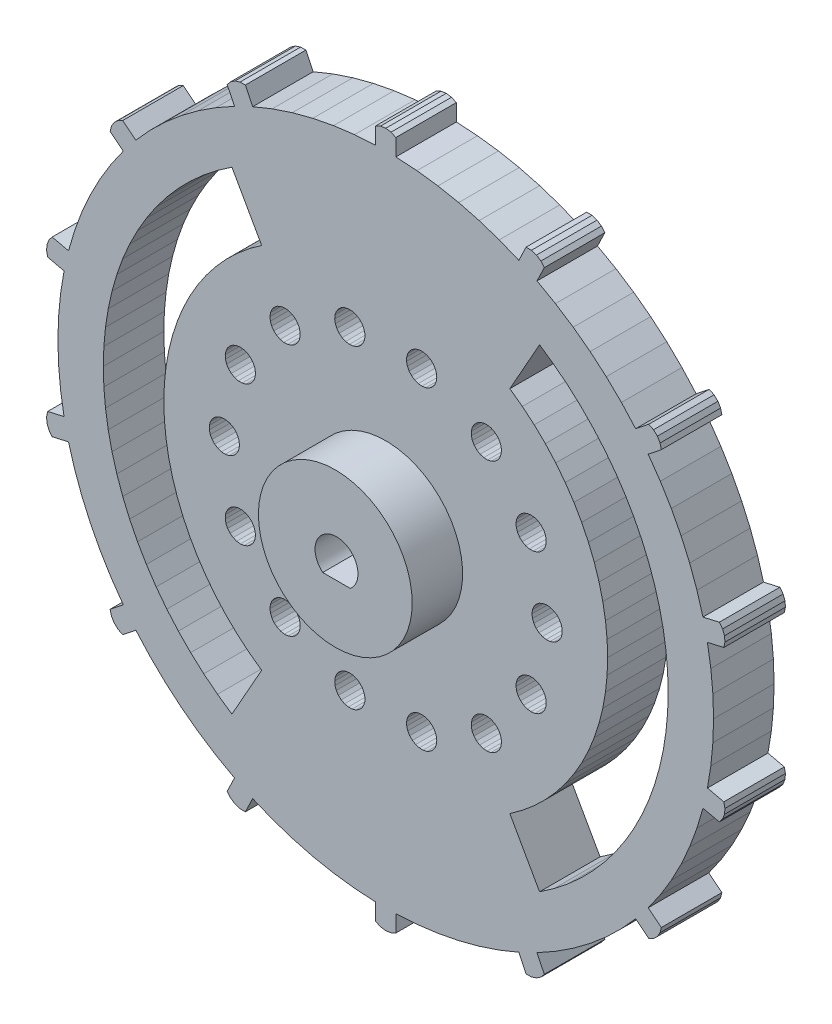
from build123d import *

# Parameters (mm, degrees)
BOSS_EXTRUDE1_DEPTH = 6.000000052
CUT_EXTRUDE1_DEPTH  = 7.000000052
CUT_EXTRUDE2_DEPTH  = 7.000000052
CUT_EXTRUDE3_DEPTH  = 7.000000052
CUT_EXTRUDE4_DEPTH  = 7.000000052
CUT_EXTRUDE5_DEPTH  = 7.000000052
CUT_EXTRUDE6_DEPTH  = 7.000000052
CUT_EXTRUDE7_DEPTH  = 7.000000052
CUT_EXTRUDE8_DEPTH  = 7.000000052
CUT_EXTRUDE9_DEPTH  = 7.000000052
CUT_EXTRUDE10_DEPTH = 7.000000052
CUT_EXTRUDE11_DEPTH = 7.000000052
CUT_EXTRUDE12_DEPTH = 7.000000052
CUT_EXTRUDE13_DEPTH = 7.000000052
CUT_EXTRUDE14_DEPTH = 7.000000052
CUT_EXTRUDE15_DEPTH = 7.000000052
CUT_EXTRUDE16_DEPTH = 7.000000052
SKETCH18_R          = 8.127
CUT_EXTRUDE17_DEPTH = 3.500000108
SKETCH19_R          = 7.623
BOSS_EXTRUDE2_DEPTH = 4.999999888
CUT_EXTRUDE18_DEPTH = 6.99999975


with BuildPart() as part:
    # Sketch1 → Boss-Extrude1 (new body)
    with BuildSketch(Plane.XY.offset(6.000000052)):
        Polygon((26.548104361, -21.838512272), (26.932541281, -21.477984264), (27.198484167, -21.022962406), (27.323946357, -20.511072129), (26.020983234, -19.471991807), (27.222689241, -17.753176391), (28.311034665, -15.960428864), (29.281487688, -14.101221226), (30.130006373, -12.1832937), (30.853059143, -10.214632377), (31.447633341, -8.203437157), (33.072403803, -8.574280493), (33.394388094, -8.157032147), (33.584325746, -7.665406983), (33.626510933, -7.140057698), (33.517445609, -6.624424901), (31.892675146, -6.253581565), (32.229609027, -4.183579307), (32.432331875, -2.096155729), (32.499998048, -3.33e-06), (32.432331875, 2.096155729), (32.229609027, 4.183579307), (31.892675146, 6.253581565), (33.517445609, 6.624424901), (33.626510933, 7.140057698), (33.584325746, 7.665406983), (33.394388094, 8.157032147), (33.072403803, 8.574280493), (31.447633341, 8.203437157), (30.853059143, 10.214632377), (30.130006373, 12.1832937), (29.281487688, 14.101221226), (28.311034665, 15.960428864), (27.222689241, 17.753176391), (26.020983234, 19.471991807), (27.323946357, 20.511072129), (27.198484167, 21.022962406), (26.932541281, 21.477984264), (26.548104361, 21.838512272), (26.076966897, 22.074734792), (24.774001911, 21.035656333), (23.365683854, 22.589705884), (21.860064939, 24.049688131), (20.263418555, 25.409523398), (18.582390621, 26.663547382), (16.823980957, 27.806539088), (14.995513484, 28.83373946), (15.718605369, 30.335254967), (15.383467078, 30.742013827), (14.946431853, 31.036587432), (14.443640597, 31.194610521), (13.916666619, 31.203022227), (13.193575665, 29.701506719), (11.250447482, 30.490612611), (9.260470048, 31.152747571), (7.231930271, 31.68515861), (5.173275247, 32.085623592), (3.093077568, 32.352477312), (1.000000047, 32.484613359), (1.000000047, 34.151166677), (0.521564332, 34.372232854), (0, 34.44801271), (-0.521564332, 34.372232854), (-1.000000047, 34.151166677), (-1.000000047, 32.484613359), (-3.093077568, 32.352477312), (-5.173275247, 32.085623592), (-7.231930271, 31.68515861), (-9.260470048, 31.152747571), (-11.250447482, 30.490612611), (-13.193575665, 29.701506719), (-13.916666619, 31.203022227), (-14.443640597, 31.194610521), (-14.946431853, 31.036587432), (-15.383467078, 30.742013827), (-15.718605369, 30.335254967), (-14.995513484, 28.83373946), (-16.823980957, 27.806539088), (-18.582390621, 26.663547382), (-20.263418555, 25.409523398), (-21.860064939, 24.049688131), (-23.365683854, 22.589705884), (-24.774001911, 21.035656333), (-26.076966897, 22.074734792), (-26.548104361, 21.838512272), (-26.932541281, 21.477984264), (-27.198484167, 21.022962406), (-27.323946357, 20.511072129), (-26.020983234, 19.471991807), (-27.222689241, 17.753176391), (-28.311034665, 15.960428864), (-29.281487688, 14.101221226), (-30.130006373, 12.1832937), (-30.853059143, 10.214632377), (-31.447634101, 8.203433827), (-33.072404563, 8.574277163), (-33.394388855, 8.157028817), (-33.584326506, 7.665403653), (-33.626511693, 7.140054367), (-33.517446369, 6.62442157), (-31.892675906, 6.253578234), (-32.229609787, 4.183575977), (-32.432332635, 2.096152399), (-32.499998808, 0), (-32.432332635, -2.096152399), (-32.229609787, -4.183575977), (-31.892675906, -6.253578234), (-33.517446369, -6.62442157), (-33.626511693, -7.140054367), (-33.584326506, -7.665403653), (-33.394388855, -8.157028817), (-33.072404563, -8.574277163), (-31.447634101, -8.203433827), (-30.853059143, -10.214632377), (-30.130006373, -12.1832937), (-29.281487688, -14.101221226), (-28.311034665, -15.960428864), (-27.222689241, -17.753176391), (-26.020983234, -19.471991807), (-27.323946357, -20.511072129), (-27.198484167, -21.022962406), (-26.932541281, -21.477984264), (-26.548104361, -21.838512272), (-26.076966897, -22.074734792), (-24.774001911, -21.035656333), (-23.365683854, -22.589705884), (-21.860064939, -24.049688131), (-20.263418555, -25.409523398), (-18.582390621, -26.663547382), (-16.823980957, -27.806539088), (-14.995513484, -28.83373946), (-15.718605369, -30.335254967), (-15.383467078, -30.742013827), (-14.946431853, -31.036587432), (-14.443640597, -31.194610521), (-13.916666619, -31.203022227), (-13.193575665, -29.701506719), (-11.250447482, -30.490612611), (-9.260470048, -31.152747571), (-7.231930271, -31.68515861), (-5.173275247, -32.085623592), (-3.093077568, -32.352477312), (-1.000000047, -32.484613359), (-1.000000047, -34.151166677), (-0.521564332, -34.372232854), (0, -34.44801271), (0.521564332, -34.372232854), (1.000000047, -34.151166677), (1.000000047, -32.484613359), (3.093077568, -32.352477312), (5.173275247, -32.085623592), (7.231930271, -31.68515861), (9.260470048, -31.152747571), (11.250447482, -30.490612611), (13.193575665, -29.701506719), (13.916666619, -31.203022227), (14.443640597, -31.194610521), (14.946431853, -31.036587432), (15.383467078, -30.742013827), (15.718605369, -30.335254967), (14.995513484, -28.83373946), (16.823980957, -27.806539088), (18.582390621, -26.663547382), (20.263418555, -25.409523398), (21.860064939, -24.049688131), (23.365683854, -22.589705884), (24.774001911, -21.035656333), (26.076966897, -22.074734792), align=None)
    extrude(amount=-BOSS_EXTRUDE1_DEPTH)

    # Sketch2 → Cut-Extrude1 (cut, through all)
    with BuildSketch(Plane.XY.offset(6.000000052)):
        Polygon((23.72914739, -14.863633551), (24.606877938, -13.360445388), (25.389511138, -11.805622838), (26.074018329, -10.205174796), (26.657754555, -8.565284312), (27.138466015, -6.892291829), (27.514291927, -5.192662589), (27.78378129, -3.472964512), (27.945892885, -1.739844331), (28.000000864, 0), (27.945892885, 1.739844331), (27.78378129, 3.472964512), (27.514291927, 5.192662589), (27.138466015, 6.892291829), (26.657754555, 8.565284312), (26.074018329, 10.205174796), (25.389511138, 11.805622838), (24.606877938, 13.360445388), (23.72914739, 14.863633551), (22.759705782, 16.309374943), (21.702306345, 17.692085356), (20.561030135, 19.006419927), (19.340289757, 20.247299224), (18.044805154, 21.409926936), (16.679581255, 22.489810362), (15.249893069, 23.482777178), (12.302244082, 18.238827586), (13.54455296, 17.336236313), (14.720872976, 16.349185258), (15.825476497, 15.282483771), (16.852978617, 14.141327702), (17.798373476, 12.931275181), (18.657058477, 11.658224277), (19.424846396, 10.328373872), (20.097998902, 8.94820597), (20.673237741, 7.524443325), (21.147755906, 6.06402196), (21.519247442, 4.57405718), (21.785898134, 3.06180818), (21.946409717, 1.534642419), (21.999999881, 0), (21.946409717, -1.534642419), (21.785898134, -3.06180818), (21.519247442, -4.57405718), (21.147755906, -6.06402196), (20.673237741, -7.524443325), (20.097998902, -8.94820597), (19.424846396, -10.328373872), (18.657058477, -11.658224277), (17.798373476, -12.931275181), (16.852978617, -14.141327702), (15.825476497, -15.282483771), (14.720872976, -16.349185258), (13.54455296, -17.336236313), (12.302244082, -18.238827586), (15.249893069, -23.482777178), (16.679581255, -22.489810362), (18.044805154, -21.409926936), (19.340289757, -20.247299224), (20.561030135, -19.006419927), (21.702306345, -17.692085356), (22.759705782, -16.309374943), align=None)
    extrude(amount=-CUT_EXTRUDE1_DEPTH, mode=Mode.SUBTRACT)

    # Sketch3 → Cut-Extrude2 (cut, through all)
    with BuildSketch(Plane.XY.offset(6.000000052)):
        Polygon((4.074770492, -17.007874325), (4.40901937, -16.835670918), (4.68994258, -16.585754231), (4.899887368, -16.273826361), (5.025663879, -15.919487923), (5.059367977, -15.545002185), (4.998882767, -15.173899941), (4.848008044, -14.829497784), (4.616224207, -14.533436857), (4.318094812, -14.304319397), (3.972352948, -14.156542718), (3.600722179, -14.099390246), (3.226553556, -14.136455022), (2.873357851, -14.265406877), (2.563327318, -14.478143305), (2.315942664, -14.761297964), (2.146747662, -15.097078867), (2.066373592, -15.464387834), (2.079870552, -15.840144828), (2.186390338, -16.20073989), (2.379240468, -16.523517668), (2.646303037, -16.788192093), (2.970797243, -16.978137195), (3.332334803, -17.081417143), (3.708197968, -17.09154062), align=None)
    extrude(amount=-CUT_EXTRUDE2_DEPTH, mode=Mode.SUBTRACT)

    # Sketch4 → Cut-Extrude3 (cut, through all)
    with BuildSketch(Plane.XY.offset(6.000000052)):
        Polygon((-2.379240468, -16.523517668), (-2.186390338, -16.20073989), (-2.079870552, -15.840144828), (-2.066373592, -15.464387834), (-2.146747662, -15.097078867), (-2.315942664, -14.761297964), (-2.563327318, -14.478143305), (-2.873357851, -14.265406877), (-3.226553556, -14.136455022), (-3.600722179, -14.099390246), (-3.972352948, -14.156542718), (-4.318094812, -14.304319397), (-4.616224207, -14.533436857), (-4.848008044, -14.829497784), (-4.998882767, -15.173899941), (-5.059367977, -15.545002185), (-5.025663879, -15.919487923), (-4.899887368, -16.273826361), (-4.68994258, -16.585754231), (-4.40901937, -16.835670918), (-4.074770492, -17.007874325), (-3.708197968, -17.09154062), (-3.332334803, -17.081417143), (-2.970797243, -16.978137195), (-2.646303037, -16.788192093), align=None)
    extrude(amount=-CUT_EXTRUDE3_DEPTH, mode=Mode.SUBTRACT)

    # Sketch5 → Cut-Extrude4 (cut, through all)
    with BuildSketch(Plane.XY.offset(6.000000052)):
        Polygon((-11.421781965, -12.908358127), (-11.27711311, -13.255413622), (-11.050680652, -13.555588201), (-10.756713338, -13.790018857), (-10.413679294, -13.943979517), (-10.043133982, -14.007793739), (-9.668360464, -13.97745125), (-9.312907234, -13.854861259), (-8.999107406, -13.647723943), (-8.746679872, -13.369055465), (-8.571484126, -13.036365621), (-8.484529331, -12.670558877), (-8.491279557, -12.294619344), (-8.59130919, -11.932170019), (-8.778333664, -11.6059836), (-9.040601552, -11.336556636), (-9.361634031, -11.140816845), (-9.721260518, -11.031065136), (-10.096880607, -11.014195159), (-10.464896448, -11.091269553), (-10.802182369, -11.257443577), (-11.087546125, -11.502277106), (-11.303056963, -11.810385622), (-11.435174383, -12.162409723), (-11.475595646, -12.536230497), align=None)
    extrude(amount=-CUT_EXTRUDE4_DEPTH, mode=Mode.SUBTRACT)

    # Sketch6 → Cut-Extrude5 (cut, through all)
    with BuildSketch(Plane.XY.offset(6.000000052)):
        Polygon((-20.673237741, -7.524443325), (-21.147755906, -6.06402196), (-21.519247442, -4.57405718), (-21.785898134, -3.06180818), (-21.946409717, -1.534642419), (-21.999999881, 0), (-21.946409717, 1.534642419), (-21.785898134, 3.06180818), (-21.519247442, 4.57405718), (-21.147755906, 6.06402196), (-20.673237741, 7.524443325), (-20.097998902, 8.94820597), (-19.424846396, 10.328373872), (-18.657058477, 11.658224277), (-17.798373476, 12.931275181), (-16.852978617, 14.141327702), (-15.825476497, 15.282483771), (-14.720872976, 16.349185258), (-13.54455296, 17.336236313), (-12.302244082, 18.238827586), (-15.249893069, 23.482777178), (-16.679581255, 22.489810362), (-18.044805154, 21.409926936), (-19.340289757, 20.247299224), (-20.561030135, 19.006419927), (-21.702306345, 17.692085356), (-22.759705782, 16.309374943), (-23.72914739, 14.863633551), (-24.606877938, 13.360445388), (-25.389511138, 11.805622838), (-26.074018329, 10.205174796), (-26.657754555, 8.565284312), (-27.138466015, 6.892291829), (-27.514291927, 5.192662589), (-27.78378129, 3.472964512), (-27.945892885, 1.739844331), (-28.000000864, 0), (-27.945892885, -1.739844331), (-27.78378129, -3.472964512), (-27.514291927, -5.192662589), (-27.138466015, -6.892291829), (-26.657754555, -8.565284312), (-26.074018329, -10.205174796), (-25.389511138, -11.805622838), (-24.606877938, -13.360445388), (-23.72914739, -14.863633551), (-22.759705782, -16.309374943), (-21.702306345, -17.692085356), (-20.561030135, -19.006419927), (-19.340289757, -20.247299224), (-18.044805154, -21.409926936), (-16.679581255, -22.489810362), (-15.249893069, -23.482777178), (-12.302244082, -18.238827586), (-13.54455296, -17.336236313), (-14.720872976, -16.349185258), (-15.825476497, -15.282483771), (-16.852978617, -14.141327702), (-17.798373476, -12.931275181), (-18.657058477, -11.658224277), (-19.424846396, -10.328373872), (-20.097998902, -8.94820597), align=None)
    extrude(amount=-CUT_EXTRUDE5_DEPTH, mode=Mode.SUBTRACT)

    # Sketch7 → Cut-Extrude6 (cut, through all)
    with BuildSketch(Plane.XY.offset(6.000000052)):
        Polygon((-15.6747289, -7.757215295), (-15.432466753, -8.044765331), (-15.126304701, -8.263032883), (-14.775481075, -8.398303762), (-14.402038418, -8.442079648), (-14.02944047, -8.391607553), (-13.681101613, -8.250061423), (-13.378907926, -8.026331663), (-13.141846284, -7.734479848), (-12.984814122, -7.392841857), (-12.917676941, -7.022884209), (-12.94465363, -6.647853646), (-13.064049184, -6.291314028), (-13.268360868, -5.975668319), (-13.544752263, -5.720749497), (-13.875855133, -5.542574916), (-14.240867458, -5.452340003), (-14.616851695, -5.455715116), (-14.980184846, -5.552487914), (-15.308036469, -5.736576859), (-15.579807572, -5.996416789), (-15.778420493, -6.315679289), (-15.891397372, -6.674304605), (-15.911636874, -7.049758919), (-15.837868676, -7.418451365), align=None)
    extrude(amount=-CUT_EXTRUDE6_DEPTH, mode=Mode.SUBTRACT)

    # Sketch8 → Cut-Extrude7 (cut, through all)
    with BuildSketch(Plane.XY.offset(6.000000052)):
        Polygon((11.435174383, -12.162409723), (11.303056963, -11.810385622), (11.087546125, -11.502277106), (10.802182369, -11.257443577), (10.464896448, -11.091269553), (10.096880607, -11.014195159), (9.721260518, -11.031065136), (9.361634031, -11.140816845), (9.040601552, -11.336556636), (8.778333664, -11.6059836), (8.59130919, -11.932170019), (8.491279557, -12.294619344), (8.484529331, -12.670558877), (8.571484126, -13.036365621), (8.746679872, -13.369055465), (8.999107406, -13.647723943), (9.312907234, -13.854861259), (9.668360464, -13.97745125), (10.043133982, -14.007793739), (10.413679294, -13.943979517), (10.756713338, -13.790018857), (11.050680652, -13.555588201), (11.27711311, -13.255413622), (11.421781965, -12.908358127), (11.475595646, -12.536230497), align=None)
    extrude(amount=-CUT_EXTRUDE7_DEPTH, mode=Mode.SUBTRACT)

    # Sketch9 → Cut-Extrude8 (cut, through all)
    with BuildSketch(Plane.XY.offset(6.000000052)):
        Polygon((14.775481075, -8.398303762), (15.126304701, -8.263032883), (15.432466753, -8.044765331), (15.6747289, -7.757215295), (15.837868676, -7.418451365), (15.911636874, -7.049758919), (15.891397372, -6.674304605), (15.778420493, -6.315679289), (15.579807572, -5.996416789), (15.308036469, -5.736576859), (14.980184846, -5.552487914), (14.616851695, -5.455715116), (14.240867458, -5.452340003), (13.875855133, -5.542574916), (13.544752263, -5.720749497), (13.268360868, -5.975668319), (13.064049184, -6.291314028), (12.94465363, -6.647853646), (12.917676941, -7.022884209), (12.984814122, -7.392841857), (13.141846284, -7.734479848), (13.378907926, -8.026331663), (13.681101613, -8.250061423), (14.02944047, -8.391607553), (14.402038418, -8.442079648), align=None)
    extrude(amount=-CUT_EXTRUDE8_DEPTH, mode=Mode.SUBTRACT)

    # Sketch10 → Cut-Extrude9 (cut, through all)
    with BuildSketch(Plane.XY.offset(6.000000052)):
        Polygon((-17.213525251, -0.881677843), (-16.956137493, -1.155769802), (-16.638668254, -1.357240602), (-16.28107205, -1.473430893), (-15.905814245, -1.497040037), (-15.536474064, -1.426584669), (-15.196259134, -1.266491832), (-14.906547032, -1.026820624), (-14.68554046, -0.722630473), (-14.547124505, -0.373034825), (-14.499999583, 0), (-14.547124505, 0.373034825), (-14.68554046, 0.722630473), (-14.906547032, 1.026820624), (-15.196259134, 1.266491832), (-15.536474064, 1.426584669), (-15.905814245, 1.497040037), (-16.28107205, 1.473430893), (-16.638668254, 1.357240602), (-16.956137493, 1.155769802), (-17.213525251, 0.881677843), (-17.394665629, 0.552186859), (-17.488172278, 0.187999845), (-17.488172278, -0.187999845), (-17.394665629, -0.552186859), align=None)
    extrude(amount=-CUT_EXTRUDE9_DEPTH, mode=Mode.SUBTRACT)

    # Sketch11 → Cut-Extrude10 (cut, through all)
    with BuildSketch(Plane.XY.offset(6.000000052)):
        Polygon((-15.308036469, 5.736576859), (-14.980184846, 5.552487914), (-14.616851695, 5.455715116), (-14.240867458, 5.452340003), (-13.875855133, 5.542574916), (-13.544752263, 5.720749497), (-13.268360868, 5.975668319), (-13.064049184, 6.291314028), (-12.94465363, 6.647853646), (-12.917676941, 7.022884209), (-12.984814122, 7.392841857), (-13.141846284, 7.734479848), (-13.378907926, 8.026331663), (-13.681101613, 8.250061423), (-14.02944047, 8.391607553), (-14.402038418, 8.442079648), (-14.775481075, 8.398303762), (-15.126304701, 8.263032883), (-15.432466753, 8.044765331), (-15.6747289, 7.757215295), (-15.837868676, 7.418451365), (-15.911636874, 7.049758919), (-15.891397372, 6.674304605), (-15.778420493, 6.315679289), (-15.579807572, 5.996416789), align=None)
    extrude(amount=-CUT_EXTRUDE10_DEPTH, mode=Mode.SUBTRACT)

    # Sketch12 → Cut-Extrude11 (cut, through all)
    with BuildSketch(Plane.XY.offset(6.000000052)):
        Polygon((16.28107205, -1.473430893), (16.638668254, -1.357240602), (16.956137493, -1.155769802), (17.213525251, -0.881677843), (17.394665629, -0.552186859), (17.488172278, -0.187999845), (17.488172278, 0.187999845), (17.394665629, 0.552186859), (17.213525251, 0.881677843), (16.956137493, 1.155769802), (16.638668254, 1.357240602), (16.28107205, 1.473430893), (15.905814245, 1.497040037), (15.536474064, 1.426584669), (15.196259134, 1.266491832), (14.906547032, 1.026820624), (14.68554046, 0.722630473), (14.547124505, 0.373034825), (14.499999583, 0), (14.547124505, -0.373034825), (14.68554046, -0.722630473), (14.906547032, -1.026820624), (15.196259134, -1.266491832), (15.536474064, -1.426584669), (15.905814245, -1.497040037), align=None)
    extrude(amount=-CUT_EXTRUDE11_DEPTH, mode=Mode.SUBTRACT)

    # Sketch13 → Cut-Extrude12 (cut, through all)
    with BuildSketch(Plane.XY.offset(6.000000052)):
        Polygon((15.308036469, 5.736576859), (15.579807572, 5.996416789), (15.778420493, 6.315679289), (15.891397372, 6.674304605), (15.911636874, 7.049758919), (15.837868676, 7.418451365), (15.6747289, 7.757215295), (15.432466753, 8.044765331), (15.126304701, 8.263032883), (14.775481075, 8.398303762), (14.402038418, 8.442079648), (14.02944047, 8.391607553), (13.681101613, 8.250061423), (13.378907926, 8.026331663), (13.141846284, 7.734479848), (12.984814122, 7.392841857), (12.917676941, 7.022884209), (12.94465363, 6.647853646), (13.064049184, 6.291314028), (13.268360868, 5.975668319), (13.544752263, 5.720749497), (13.875855133, 5.542574916), (14.240867458, 5.452340003), (14.616851695, 5.455715116), (14.980184846, 5.552487914), align=None)
    extrude(amount=-CUT_EXTRUDE12_DEPTH, mode=Mode.SUBTRACT)

    # Sketch14 → Cut-Extrude13 (cut, through all)
    with BuildSketch(Plane.XY.offset(6.000000052)):
        Polygon((-10.096880607, 11.014195159), (-9.721260518, 11.031065136), (-9.361634031, 11.140816845), (-9.040601552, 11.336556636), (-8.778333664, 11.6059836), (-8.59130919, 11.932170019), (-8.491279557, 12.294619344), (-8.484529331, 12.670558877), (-8.571484126, 13.036365621), (-8.746679872, 13.369055465), (-8.999107406, 13.647723943), (-9.312907234, 13.854861259), (-9.668360464, 13.97745125), (-10.043133982, 14.007793739), (-10.413679294, 13.943979517), (-10.756713338, 13.790018857), (-11.050680652, 13.555588201), (-11.27711311, 13.255413622), (-11.421781965, 12.908358127), (-11.475595646, 12.536230497), (-11.435174383, 12.162409723), (-11.303056963, 11.810385622), (-11.087546125, 11.502277106), (-10.802182369, 11.257443577), (-10.464896448, 11.091269553), align=None)
    extrude(amount=-CUT_EXTRUDE13_DEPTH, mode=Mode.SUBTRACT)

    # Sketch15 → Cut-Extrude14 (cut, through all)
    with BuildSketch(Plane.XY.offset(6.000000052)):
        Polygon((8.778333664, 11.6059836), (9.040601552, 11.336556636), (9.361634031, 11.140816845), (9.721260518, 11.031065136), (10.096880607, 11.014195159), (10.464896448, 11.091269553), (10.802182369, 11.257443577), (11.087546125, 11.502277106), (11.303056963, 11.810385622), (11.435174383, 12.162409723), (11.475595646, 12.536230497), (11.421781965, 12.908358127), (11.27711311, 13.255413622), (11.050680652, 13.555588201), (10.756713338, 13.790018857), (10.413679294, 13.943979517), (10.043133982, 14.007793739), (9.668360464, 13.97745125), (9.312907234, 13.854861259), (8.999107406, 13.647723943), (8.746679872, 13.369055465), (8.571484126, 13.036365621), (8.484529331, 12.670558877), (8.491279557, 12.294619344), (8.59130919, 11.932170019), align=None)
    extrude(amount=-CUT_EXTRUDE14_DEPTH, mode=Mode.SUBTRACT)

    # Sketch16 → Cut-Extrude15 (cut, through all)
    with BuildSketch(Plane.XY.offset(6.000000052)):
        Polygon((-3.600722179, 14.099390246), (-3.226553556, 14.136455022), (-2.873357851, 14.265406877), (-2.563327318, 14.478143305), (-2.315942664, 14.761297964), (-2.146747662, 15.097078867), (-2.066373592, 15.464387834), (-2.079870552, 15.840144828), (-2.186390338, 16.20073989), (-2.379240468, 16.523517668), (-2.646303037, 16.788192093), (-2.970797243, 16.978137195), (-3.332334803, 17.081417143), (-3.708197968, 17.09154062), (-4.074770492, 17.007874325), (-4.40901937, 16.835670918), (-4.68994258, 16.585754231), (-4.899887368, 16.273826361), (-5.025663879, 15.919487923), (-5.059367977, 15.545002185), (-4.998882767, 15.173899941), (-4.848008044, 14.829497784), (-4.616224207, 14.533436857), (-4.318094812, 14.304319397), (-3.972352948, 14.156542718), align=None)
    extrude(amount=-CUT_EXTRUDE15_DEPTH, mode=Mode.SUBTRACT)

    # Sketch17 → Cut-Extrude16 (cut, through all)
    with BuildSketch(Plane(origin=(0, 0, 0), x_dir=(-1, 0, 0), z_dir=(0, 0, -1))):
        Polygon((-3.600722179, 14.099390246), (-3.226553556, 14.136455022), (-2.873357851, 14.265406877), (-2.563327318, 14.478143305), (-2.315942664, 14.761297964), (-2.146747662, 15.097078867), (-2.066373592, 15.464387834), (-2.079870552, 15.840144828), (-2.186390338, 16.20073989), (-2.379240468, 16.523517668), (-2.646303037, 16.788192093), (-2.970797243, 16.978137195), (-3.332334803, 17.081417143), (-3.708197968, 17.09154062), (-4.074770492, 17.007874325), (-4.40901937, 16.835670918), (-4.68994258, 16.585754231), (-4.899887368, 16.273826361), (-5.025663879, 15.919487923), (-5.059367977, 15.545002185), (-4.998882767, 15.173899941), (-4.848008044, 14.829497784), (-4.616224207, 14.533436857), (-4.318094812, 14.304319397), (-3.972352948, 14.156542718), align=None)
    extrude(amount=-CUT_EXTRUDE16_DEPTH, mode=Mode.SUBTRACT)

    # Sketch18 → Cut-Extrude17 (cut)
    with BuildSketch(Plane(origin=(0, 0, 0), x_dir=(-1, 0, 0), z_dir=(0, 0, -1))):
        Circle(SKETCH18_R)
    extrude(amount=-CUT_EXTRUDE17_DEPTH, mode=Mode.SUBTRACT)

    # Sketch19 → Boss-Extrude2 (add)
    with BuildSketch(Plane.XY.offset(6.000000052)):
        Circle(SKETCH19_R)
    extrude(amount=BOSS_EXTRUDE2_DEPTH)

    # Sketch20 → Cut-Extrude18 (cut)
    with BuildSketch(Plane.XY.offset(10.99999994)):
        with BuildLine():
            Line((1.488963448, -1.817092008), (-1.251109543, -1.817092008))
            ThreePointArc((-1.251109543, -1.817092008), (0.118926953, 1.936907992), (1.488963448, -1.817092008))
        make_face()
    extrude(amount=-CUT_EXTRUDE18_DEPTH, mode=Mode.SUBTRACT)


solid = part.part
